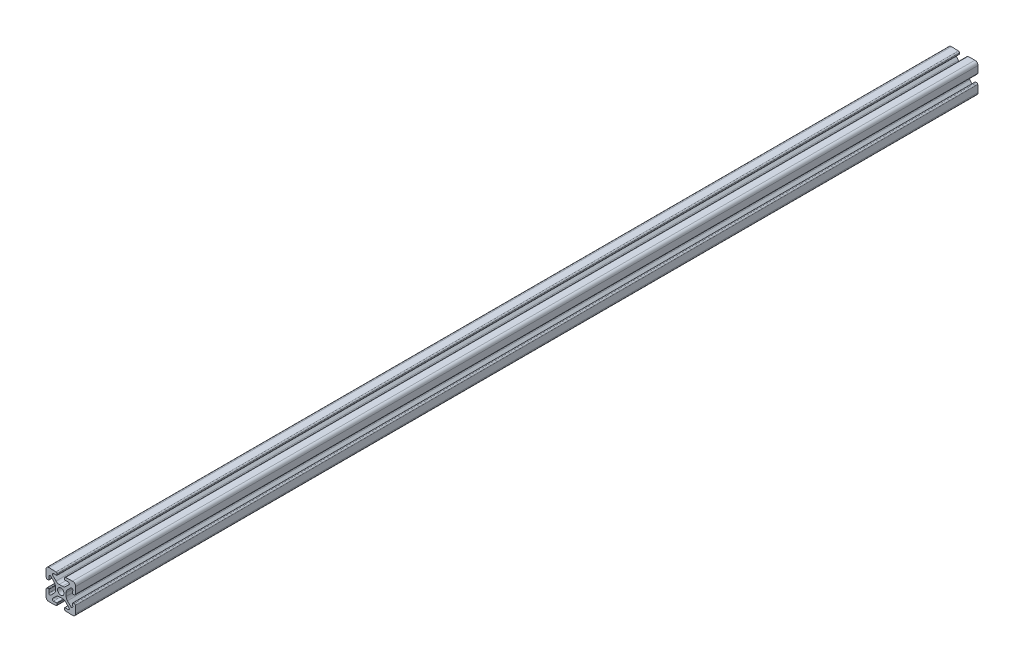
from build123d import *

# Parameters (mm, degrees)
BOSS_EXTRUDE1_DEPTH = 304.8
CIRPATTERN1_COUNT   = 4


with BuildPart() as part:
    # Sketch3 → Boss-Extrude1 (new body, symmetric)
    with BuildSketch(Plane.XY):
        with BuildLine():
            Line((-2.524916986, 8.30911066), (-2.500487338, 9.008684239))
            ThreePointArc((-2.500487338, 9.008684239), (-2.714917039, 9.582202525), (-3.272080403, 9.836116498))
            Line((-3.272080403, 9.836116498), (-7.930201007, 9.998781654))
            ThreePointArc((-7.930201007, 9.998781654), (-9.414213562, 9.414213562), (-9.998781654, 7.930201007))
            Line((-9.998781654, 7.930201007), (-9.836116498, 3.272080403))
            ThreePointArc((-9.836116498, 3.272080403), (-9.582202525, 2.714917039), (-9.008684239, 2.500487338))
            Line((-9.008684239, 2.500487338), (-8.30911066, 2.524916986))
            ThreePointArc((-8.30911066, 2.524916986), (-8.100174399, 2.620134726), (-8.019763261, 2.835204083))
            Line((-8.019763261, 2.835204083), (-8.093719461, 4.953032548))
            ThreePointArc((-8.093719461, 4.953032548), (-7.631170264, 5.686128657), (-6.779559917, 5.52444538))
            Line((-6.779559917, 5.52444538), (-4.478679656, 3.22356512))
            ThreePointArc((-4.478679656, 3.22356512), (-3.828361402, 2.250295073), (-3.6, 1.102244776))
            Line((-3.6, 1.102244776), (-3.6, 0))
            Line((-3.6, 0), (-2.15, 0))
            ThreePointArc((-2.15, 0), (-1.52027958, 1.52027958), (0, 2.15))
            Line((0, 2.15), (0, 3.6))
            Line((0, 3.6), (-1.102244776, 3.6))
            ThreePointArc((-1.102244776, 3.6), (-2.250295073, 3.828361402), (-3.22356512, 4.478679656))
            Line((-3.22356512, 4.478679656), (-5.52444538, 6.779559917))
            ThreePointArc((-5.52444538, 6.779559917), (-5.686128657, 7.631170264), (-4.953032548, 8.093719461))
            Line((-4.953032548, 8.093719461), (-2.835204083, 8.019763261))
            ThreePointArc((-2.835204083, 8.019763261), (-2.620134726, 8.100174399), (-2.524916986, 8.30911066))
        make_face()
    boss_extrude1 = extrude(amount=BOSS_EXTRUDE1_DEPTH, both=True)

    # CirPattern1: Boss-Extrude1 ×4 about axis
    cirpattern1_axis = Axis((0, 0, 0), (0, 0, 1))
    for i in range(1, CIRPATTERN1_COUNT):
        add(boss_extrude1.rotate(cirpattern1_axis, i * 360 / CIRPATTERN1_COUNT))


solid = part.part
